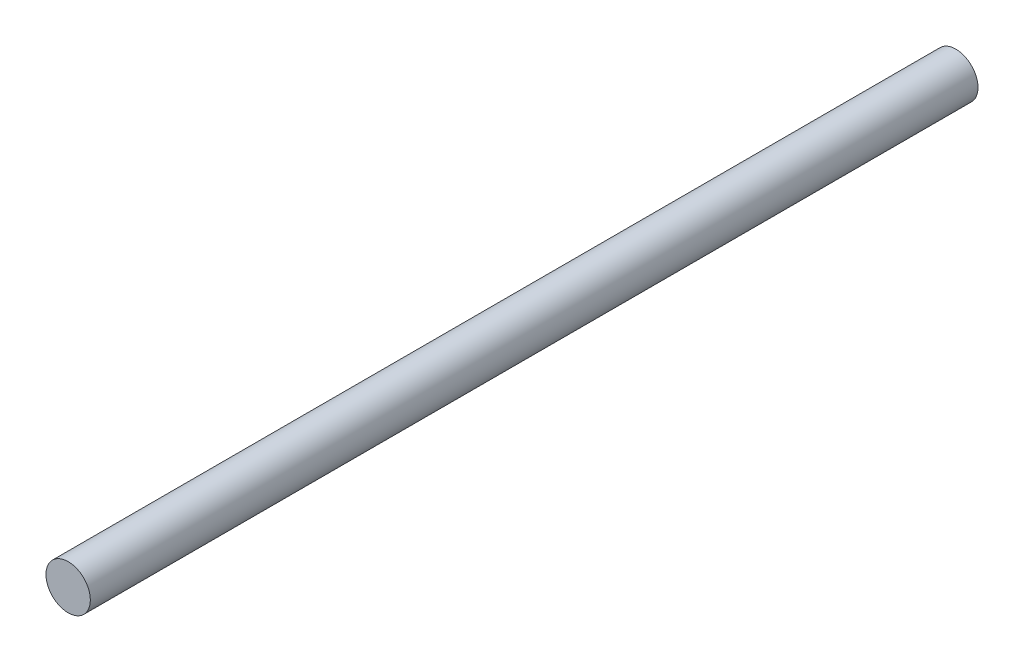
from build123d import *

# Parameters (mm, degrees)
SKETCH1_R           = 12.5
BOSS_EXTRUDE1_DEPTH = 500


with BuildPart() as part:
    # Sketch1 → Boss-Extrude1 (new body)
    with BuildSketch(Plane.XY):
        Circle(SKETCH1_R)
    extrude(amount=-BOSS_EXTRUDE1_DEPTH)


solid = part.part
